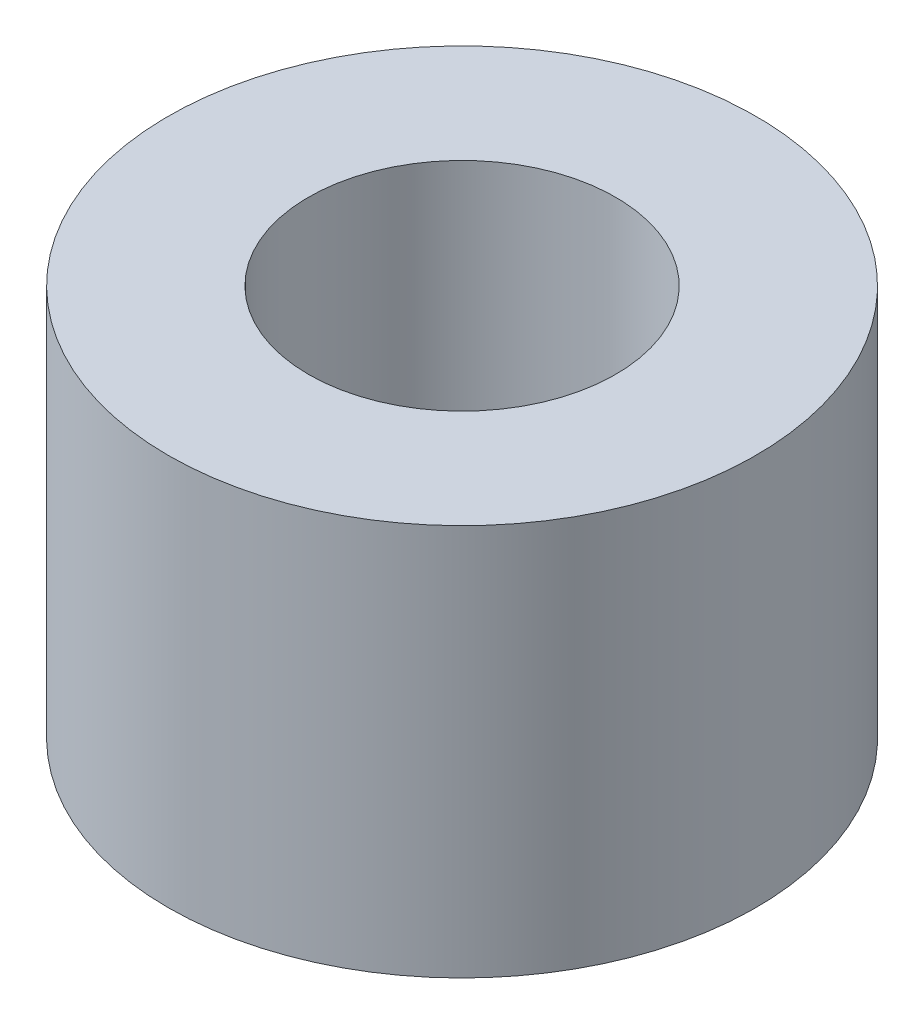
from build123d import *

# Parameters (mm, degrees)
SKETCH1_R           = 4.7625
SKETCH1_R_2         = 2.4892
BOSS_EXTRUDE1_DEPTH = 6.35


with BuildPart() as part:
    # Sketch1 → Boss-Extrude1 (new body)
    with BuildSketch(Plane(origin=(0, 0, 0), x_dir=(1, 0, 0), z_dir=(0, 1, 0))):
        Circle(SKETCH1_R)
        Circle(SKETCH1_R_2, mode=Mode.SUBTRACT)
    extrude(amount=BOSS_EXTRUDE1_DEPTH)


solid = part.part
